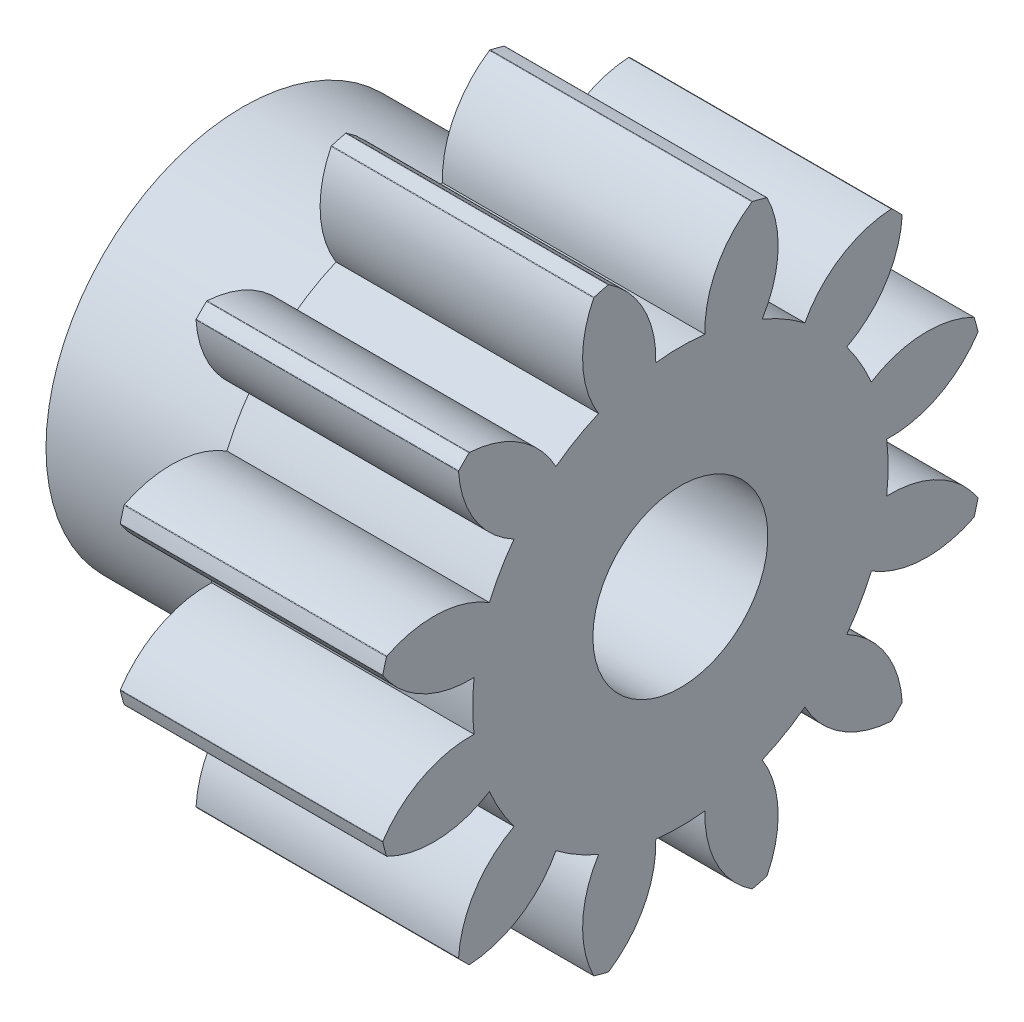
from build123d import *

# Parameters (mm, degrees)
BASPROSKE_W           = 6
BASPROSKE_H           = 7
TOOTHCUT_DEPTH        = 12.575836903
BREAKS_R              = 0.02
TEETHCUTS_COUNT       = 12
BREAKS_OF_TEETHCUTS_R = 0.02
BORSKE_R              = 2
BORE_DEPTH            = 50.0000508
SKETCH_3_R            = 4.5
EXTRUDE_2_DEPTH       = 4


with BuildPart() as part:
    # BasProSke → Base-Revolve (revolve)
    with BuildSketch(Plane(origin=(0, 0, 0), x_dir=(1, 0, 0), z_dir=(0, 1, 0)), mode=Mode.PRIVATE) as base_revolve_sk:
        with Locations((3, 3.5)):
            Rectangle(BASPROSKE_W, BASPROSKE_H)
    revolve(base_revolve_sk.sketch.rotate(Axis((-10, 0, 0), (1, 0, 0)), 180), axis=Axis((-10, 0, 0), (1, 0, 0)))

    # TooCutSke → ToothCut (cut, through all)
    with BuildSketch(Plane(origin=(0, 0, 0), x_dir=(0, 0, -1), z_dir=(1, 0, 0))):
        with BuildLine():
            ThreePointArc((0.562207301, 4.715604304), (0, 4.749), (-0.562207301, 4.715604304))
            ThreePointArc((-0.562207301, 4.715604304), (-0.837528627, 5.917009812), (-1.672850686, 6.823328788))
            ThreePointArc((-1.672850686, 6.823328788), (0, 7.0254), (1.672850686, 6.823328788))
            ThreePointArc((1.672850686, 6.823328788), (0.837528627, 5.917009812), (0.562207301, 4.715604304))
        make_face()
    toothcut = extrude(amount=TOOTHCUT_DEPTH, mode=Mode.SUBTRACT)

    # Breaks
    breaks_edges = [part.edges().sort_by_distance(p)[0] for p in [
        (3, 6.804338411, -1.643465482),
        (3, 6.804338411, 1.643465482),
    ]]
    fillet(breaks_edges, radius=BREAKS_R)

    # TeethCuts: ToothCut ×12 about axis
    teethcuts_axis = Axis((0, 0, 0), (1, 0, 0))
    for i in range(1, TEETHCUTS_COUNT):
        add(toothcut.rotate(teethcuts_axis, i * 360 / TEETHCUTS_COUNT), mode=Mode.SUBTRACT)

    # Breaks of TeethCuts
    breaks_of_teethcuts_edges = [part.edges().sort_by_distance(p)[0] for p in [
        (3, 6.714462661, 1.978886348),
        (3, 5.070997179, 4.825452063),
        (3, 4.825452063, 5.070997179),
        (3, 1.978886348, 6.714462661),
        (3, 1.643465482, 6.804338411),
        (3, -1.643465482, 6.804338411),
        (3, -1.978886348, 6.714462661),
        (3, -4.825452063, 5.070997179),
        (3, -5.070997179, 4.825452063),
        (3, -6.714462661, 1.978886348),
        (3, -6.804338411, 1.643465482),
        (3, -6.804338411, -1.643465482),
        (3, -6.714462661, -1.978886348),
        (3, -5.070997179, -4.825452063),
        (3, -4.825452063, -5.070997179),
        (3, -1.978886348, -6.714462661),
        (3, -1.643465482, -6.804338411),
        (3, 1.643465482, -6.804338411),
        (3, 1.978886348, -6.714462661),
        (3, 4.825452063, -5.070997179),
        (3, 5.070997179, -4.825452063),
        (3, 6.714462661, -1.978886348),
    ]]
    fillet(breaks_of_teethcuts_edges, radius=BREAKS_OF_TEETHCUTS_R)

    # BorSke → Bore (cut, symmetric)
    with BuildSketch(Plane(origin=(0, 0, 0), x_dir=(0, 0, -1), z_dir=(1, 0, 0))):
        with Locations(Location((0, 0, 0), (0, 0, 180))):
            Circle(BORSKE_R)
    extrude(amount=BORE_DEPTH, both=True, mode=Mode.SUBTRACT)


with BuildPart() as body_2:
    # Эскиз3 → Бобышка-Вытянуть2 (new body)
    with BuildSketch(Plane.ZY.offset(4)):
        Circle(SKETCH_3_R)
        with BuildLine():
            ThreePointArc((-0.876147315, 2.018010377), (-0.823286315, 2.040146966), (-0.769866652, 2.060899158))
            Line((-0.769866652, 2.060899158), (-0.723029135, 2.393162943))
            ThreePointArc((-0.723029135, 2.393162943), (-0.561364767, 2.436158779), (-0.397186922, 2.468246857))
            Line((-0.397186922, 2.468246857), (-0.209666112, 2.189986329))
            ThreePointArc((-0.209666112, 2.189986329), (-0.152551731, 2.194704529), (-0.095333833, 2.197933452))
            Line((-0.095333833, 2.197933452), (0.051886449, 2.499461501))
            ThreePointArc((0.051886449, 2.499461501), (0.218924844, 2.490395935), (0.384983015, 2.470179766))
            Line((0.384983015, 2.470179766), (0.477338671, 2.147591161))
            ThreePointArc((0.477338671, 2.147591161), (0.533115679, 2.134429121), (0.588530927, 2.119818707))
            Line((0.588530927, 2.119818707), (0.821723026, 2.361095353))
            ThreePointArc((0.821723026, 2.361095353), (0.977784566, 2.300855785), (1.129468132, 2.230314269))
            Line((1.129468132, 2.230314269), (1.117618219, 1.894974806))
            ThreePointArc((1.117618219, 1.894974806), (1.166598012, 1.865220919), (1.214786178, 1.834201336))
            Line((1.214786178, 1.834201336), (1.511123628, 1.991608742))
            ThreePointArc((1.511123628, 1.991608742), (1.640931922, 1.88609184), (1.763393039, 1.772130071))
            Line((1.763393039, 1.772130071), (1.648497509, 1.456865115))
            ThreePointArc((1.648497509, 1.456865115), (1.685885604, 1.413431898), (1.722129695, 1.369039559))
            Line((1.722129695, 1.369039559), (2.052604921, 1.42716959))
            ThreePointArc((2.052604921, 1.42716959), (2.143453429, 1.286704084), (2.224704749, 1.140477435))
            Line((2.224704749, 1.140477435), (2.018010377, 0.876147315))
            ThreePointArc((2.018010377, 0.876147315), (2.040146966, 0.823286315), (2.060899158, 0.769866652))
            Line((2.060899158, 0.769866652), (2.393162943, 0.723029135))
            ThreePointArc((2.393162943, 0.723029135), (2.436158779, 0.561364767), (2.468246857, 0.397186922))
            Line((2.468246857, 0.397186922), (2.189986329, 0.209666112))
            ThreePointArc((2.189986329, 0.209666112), (2.194704529, 0.152551731), (2.197933452, 0.095333833))
            Line((2.197933452, 0.095333833), (2.499461501, -0.051886449))
            ThreePointArc((2.499461501, -0.051886449), (2.490395935, -0.218924844), (2.470179766, -0.384983015))
            Line((2.470179766, -0.384983015), (2.147591161, -0.477338671))
            ThreePointArc((2.147591161, -0.477338671), (2.134429121, -0.533115679), (2.119818707, -0.588530927))
            Line((2.119818707, -0.588530927), (2.361095353, -0.821723026))
            ThreePointArc((2.361095353, -0.821723026), (2.300855785, -0.977784566), (2.230314269, -1.129468132))
            Line((2.230314269, -1.129468132), (1.894974806, -1.117618219))
            ThreePointArc((1.894974806, -1.117618219), (1.865220919, -1.166598012), (1.834201336, -1.214786178))
            Line((1.834201336, -1.214786178), (1.991608742, -1.511123628))
            ThreePointArc((1.991608742, -1.511123628), (1.88609184, -1.640931922), (1.772130071, -1.763393039))
            Line((1.772130071, -1.763393039), (1.456865115, -1.648497509))
            ThreePointArc((1.456865115, -1.648497509), (1.413431898, -1.685885604), (1.369039559, -1.722129695))
            Line((1.369039559, -1.722129695), (1.42716959, -2.052604921))
            ThreePointArc((1.42716959, -2.052604921), (1.286704084, -2.143453429), (1.140477435, -2.224704749))
            Line((1.140477435, -2.224704749), (0.876147315, -2.018010377))
            ThreePointArc((0.876147315, -2.018010377), (0.823286315, -2.040146966), (0.769866652, -2.060899158))
            Line((0.769866652, -2.060899158), (0.723029135, -2.393162943))
            ThreePointArc((0.723029135, -2.393162943), (0.561364767, -2.436158779), (0.397186922, -2.468246857))
            Line((0.397186922, -2.468246857), (0.209666112, -2.189986329))
            ThreePointArc((0.209666112, -2.189986329), (0.152551731, -2.194704529), (0.095333833, -2.197933452))
            Line((0.095333833, -2.197933452), (-0.051886449, -2.499461501))
            ThreePointArc((-0.051886449, -2.499461501), (-0.218924844, -2.490395935), (-0.384983015, -2.470179766))
            Line((-0.384983015, -2.470179766), (-0.477338671, -2.147591161))
            ThreePointArc((-0.477338671, -2.147591161), (-0.533115679, -2.134429121), (-0.588530927, -2.119818707))
            Line((-0.588530927, -2.119818707), (-0.821723026, -2.361095353))
            ThreePointArc((-0.821723026, -2.361095353), (-0.977784566, -2.300855785), (-1.129468132, -2.230314269))
            Line((-1.129468132, -2.230314269), (-1.117618219, -1.894974806))
            ThreePointArc((-1.117618219, -1.894974806), (-1.166598012, -1.865220919), (-1.214786178, -1.834201336))
            Line((-1.214786178, -1.834201336), (-1.511123628, -1.991608742))
            ThreePointArc((-1.511123628, -1.991608742), (-1.640931922, -1.88609184), (-1.763393039, -1.772130071))
            Line((-1.763393039, -1.772130071), (-1.648497509, -1.456865115))
            ThreePointArc((-1.648497509, -1.456865115), (-1.685885604, -1.413431898), (-1.722129695, -1.369039559))
            Line((-1.722129695, -1.369039559), (-2.052604921, -1.42716959))
            ThreePointArc((-2.052604921, -1.42716959), (-2.143453429, -1.286704084), (-2.224704749, -1.140477435))
            Line((-2.224704749, -1.140477435), (-2.018010377, -0.876147315))
            ThreePointArc((-2.018010377, -0.876147315), (-2.040146966, -0.823286315), (-2.060899158, -0.769866652))
            Line((-2.060899158, -0.769866652), (-2.393162943, -0.723029135))
            ThreePointArc((-2.393162943, -0.723029135), (-2.436158779, -0.561364767), (-2.468246857, -0.397186922))
            Line((-2.468246857, -0.397186922), (-2.189986329, -0.209666112))
            ThreePointArc((-2.189986329, -0.209666112), (-2.194704529, -0.152551731), (-2.197933452, -0.095333833))
            Line((-2.197933452, -0.095333833), (-2.499461501, 0.051886449))
            ThreePointArc((-2.499461501, 0.051886449), (-2.490395935, 0.218924844), (-2.470179766, 0.384983015))
            Line((-2.470179766, 0.384983015), (-2.147591161, 0.477338671))
            ThreePointArc((-2.147591161, 0.477338671), (-2.134429121, 0.533115679), (-2.119818707, 0.588530927))
            Line((-2.119818707, 0.588530927), (-2.361095353, 0.821723026))
            ThreePointArc((-2.361095353, 0.821723026), (-2.300855785, 0.977784566), (-2.230314269, 1.129468132))
            Line((-2.230314269, 1.129468132), (-1.894974806, 1.117618219))
            ThreePointArc((-1.894974806, 1.117618219), (-1.865220919, 1.166598012), (-1.834201336, 1.214786178))
            Line((-1.834201336, 1.214786178), (-1.991608742, 1.511123628))
            ThreePointArc((-1.991608742, 1.511123628), (-1.88609184, 1.640931922), (-1.772130071, 1.763393039))
            Line((-1.772130071, 1.763393039), (-1.456865115, 1.648497509))
            ThreePointArc((-1.456865115, 1.648497509), (-1.413431898, 1.685885604), (-1.369039559, 1.722129695))
            Line((-1.369039559, 1.722129695), (-1.42716959, 2.052604921))
            ThreePointArc((-1.42716959, 2.052604921), (-1.286704084, 2.143453429), (-1.140477435, 2.224704749))
            Line((-1.140477435, 2.224704749), (-0.876147315, 2.018010377))
        make_face(mode=Mode.SUBTRACT)
    extrude(amount=-EXTRUDE_2_DEPTH)


solid = Compound([part.part, body_2.part])
